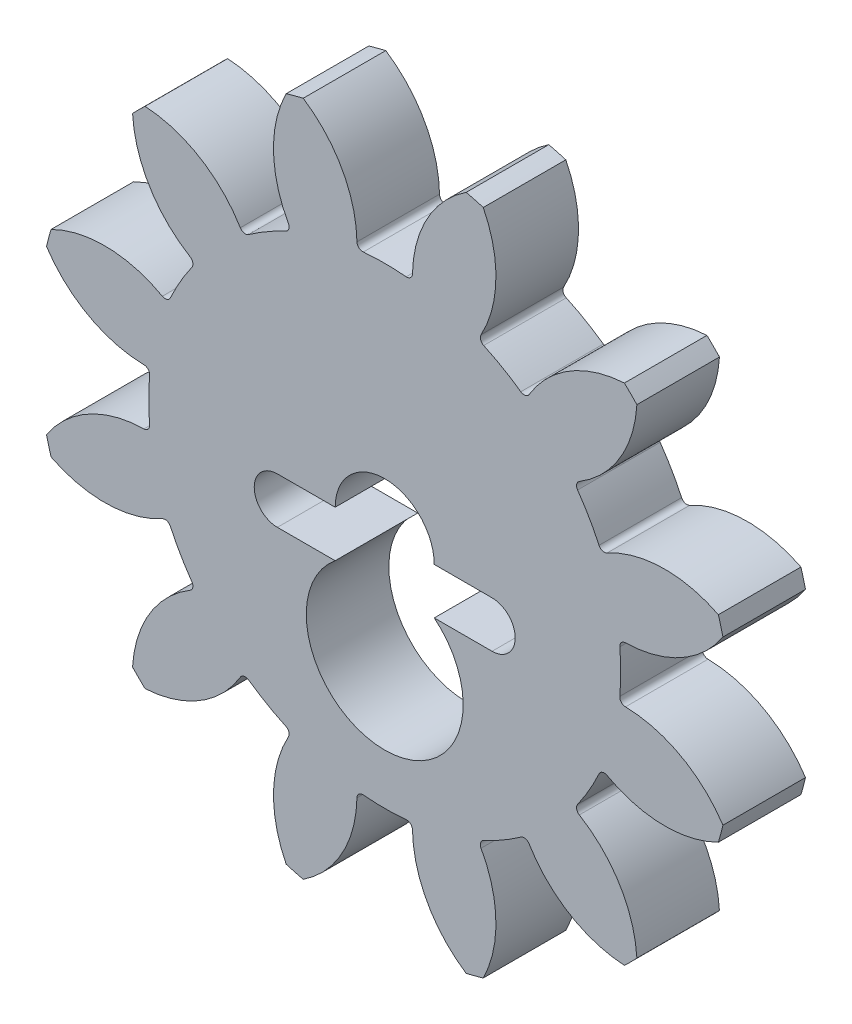
from build123d import *

# Parameters (mm, degrees)
BOSS_EXTRUDE1_DEPTH = 2.54
FILLET1_R           = 0.1778


with BuildPart() as part:
    # Sketch1 → Boss-Extrude1 (new body)
    with BuildSketch(Plane.XY):
        with BuildLine():
            ThreePointArc((-7.372965122, 7.75726334), (-7.56755407, 7.56755407), (-7.75726334, 7.372965122))
            ThreePointArc((-7.75726334, 7.372965122), (-7.183443639, 5.605840676), (-5.817551904, 4.346341719))
            ThreePointArc((-5.817551904, 4.346341719), (-6.288954394, 3.630929512), (-6.672818294, 2.864976877))
            ThreePointArc((-6.672818294, 2.864976877), (-8.446522255, 3.41812434), (-10.263806767, 3.031504555))
            ThreePointArc((-10.263806767, 3.031504555), (-10.337471104, 2.769917034), (-10.404469677, 2.506543427))
            ThreePointArc((-10.404469677, 2.506543427), (-9.023965016, 1.263078615), (-7.211318596, 0.85526639))
            ThreePointArc((-7.211318596, 0.85526639), (-7.261859025, 0), (-7.211318596, -0.85526639))
            ThreePointArc((-7.211318596, -0.85526639), (-9.023965016, -1.263078615), (-10.404469677, -2.506543427))
            ThreePointArc((-10.404469677, -2.506543427), (-10.337471104, -2.769917034), (-10.263806767, -3.031504555))
            ThreePointArc((-10.263806767, -3.031504555), (-8.446522255, -3.41812434), (-6.672818294, -2.864976877))
            ThreePointArc((-6.672818294, -2.864976877), (-6.288954394, -3.630929512), (-5.817551904, -4.346341719))
            ThreePointArc((-5.817551904, -4.346341719), (-7.183443639, -5.605840676), (-7.75726334, -7.372965122))
            ThreePointArc((-7.75726334, -7.372965122), (-7.56755407, -7.56755407), (-7.372965122, -7.75726334))
            ThreePointArc((-7.372965122, -7.75726334), (-5.605840676, -7.183443639), (-4.346341719, -5.817551904))
            ThreePointArc((-4.346341719, -5.817551904), (-3.630929512, -6.288954394), (-2.864976877, -6.672818294))
            ThreePointArc((-2.864976877, -6.672818294), (-3.41812434, -8.446522255), (-3.031504555, -10.263806767))
            ThreePointArc((-3.031504555, -10.263806767), (-2.769917034, -10.337471104), (-2.506543427, -10.404469677))
            ThreePointArc((-2.506543427, -10.404469677), (-1.263078615, -9.023965016), (-0.85526639, -7.211318596))
            ThreePointArc((-0.85526639, -7.211318596), (0, -7.261859025), (0.85526639, -7.211318596))
            ThreePointArc((0.85526639, -7.211318596), (1.263078615, -9.023965016), (2.506543427, -10.404469677))
            ThreePointArc((2.506543427, -10.404469677), (2.769917034, -10.337471104), (3.031504555, -10.263806767))
            ThreePointArc((3.031504555, -10.263806767), (3.41812434, -8.446522255), (2.864976877, -6.672818294))
            ThreePointArc((2.864976877, -6.672818294), (3.630929512, -6.288954394), (4.346341719, -5.817551904))
            ThreePointArc((4.346341719, -5.817551904), (5.605840676, -7.183443639), (7.372965122, -7.75726334))
            ThreePointArc((7.372965122, -7.75726334), (7.56755407, -7.56755407), (7.75726334, -7.372965122))
            ThreePointArc((7.75726334, -7.372965122), (7.183443639, -5.605840676), (5.817551904, -4.346341719))
            ThreePointArc((5.817551904, -4.346341719), (6.288954394, -3.630929512), (6.672818294, -2.864976877))
            ThreePointArc((6.672818294, -2.864976877), (8.446522255, -3.41812434), (10.263806767, -3.031504555))
            ThreePointArc((10.263806767, -3.031504555), (10.337471104, -2.769917034), (10.404469677, -2.506543427))
            ThreePointArc((10.404469677, -2.506543427), (9.023965016, -1.263078615), (7.211318596, -0.85526639))
            ThreePointArc((7.211318596, -0.85526639), (7.261859025, 0), (7.211318596, 0.85526639))
            ThreePointArc((7.211318596, 0.85526639), (9.023965016, 1.263078615), (10.404469677, 2.506543427))
            ThreePointArc((10.404469677, 2.506543427), (10.337471104, 2.769917034), (10.263806767, 3.031504555))
            ThreePointArc((10.263806767, 3.031504555), (8.446522255, 3.41812434), (6.672818294, 2.864976877))
            ThreePointArc((6.672818294, 2.864976877), (6.288954394, 3.630929512), (5.817551904, 4.346341719))
            ThreePointArc((5.817551904, 4.346341719), (7.183443639, 5.605840676), (7.75726334, 7.372965122))
            ThreePointArc((7.75726334, 7.372965122), (7.56755407, 7.56755407), (7.372965122, 7.75726334))
            ThreePointArc((7.372965122, 7.75726334), (5.605840676, 7.183443639), (4.346341719, 5.817551904))
            ThreePointArc((4.346341719, 5.817551904), (3.630929512, 6.288954394), (2.864976877, 6.672818294))
            ThreePointArc((2.864976877, 6.672818294), (3.41812434, 8.446522255), (3.031504555, 10.263806767))
            ThreePointArc((3.031504555, 10.263806767), (2.769917034, 10.337471104), (2.506543427, 10.404469677))
            ThreePointArc((2.506543427, 10.404469677), (1.263078615, 9.023965016), (0.85526639, 7.211318596))
            ThreePointArc((0.85526639, 7.211318596), (0, 7.261859025), (-0.85526639, 7.211318596))
            ThreePointArc((-0.85526639, 7.211318596), (-1.263078615, 9.023965016), (-2.506543427, 10.404469677))
            ThreePointArc((-2.506543427, 10.404469677), (-2.769917034, 10.337471104), (-3.031504555, 10.263806767))
            ThreePointArc((-3.031504555, 10.263806767), (-3.41812434, 8.446522255), (-2.864976877, 6.672818294))
            ThreePointArc((-2.864976877, 6.672818294), (-3.630929512, 6.288954394), (-4.346341719, 5.817551904))
            ThreePointArc((-4.346341719, 5.817551904), (-5.605840676, 7.183443639), (-7.372965122, 7.75726334))
        make_face()
        with BuildLine():
            Line((-1.524, -1.424354318), (-3.302, -1.424354318))
            ThreePointArc((-3.302, -1.424354318), (-4.014177159, -0.712177159), (-3.302, 0))
            Line((-3.302, 0), (-1.524, 0))
            ThreePointArc((-1.524, 0), (0, 1.524), (1.524, 0))
            Line((1.524, 0), (3.302, 0))
            ThreePointArc((3.302, 0), (4.014177159, -0.712177159), (3.302, -1.424354318))
            Line((3.302, -1.424354318), (1.524, -1.424354318))
            ThreePointArc((1.524, -1.424354318), (0, -5.70818114), (-1.524, -1.424354318))
        make_face(mode=Mode.SUBTRACT)
    extrude(amount=BOSS_EXTRUDE1_DEPTH)

    # Fillet1
    fillet1_edges = [part.edges().sort_by_distance(p)[0] for p in [
        (-4.346341719, 5.817551904, 1.27),
        (-2.864976877, 6.672818294, 1.27),
        (-0.85526639, 7.211318596, 1.27),
        (0.85526639, 7.211318596, 1.27),
        (2.864976877, 6.672818294, 1.27),
        (4.346341719, 5.817551904, 1.27),
        (5.817551904, 4.346341719, 1.27),
        (6.672818294, 2.864976877, 1.27),
        (7.211318596, 0.85526639, 1.27),
        (7.211318596, -0.85526639, 1.27),
        (6.672818294, -2.864976877, 1.27),
        (5.817551904, -4.346341719, 1.27),
        (4.346341719, -5.817551904, 1.27),
        (2.864976877, -6.672818294, 1.27),
        (0.85526639, -7.211318596, 1.27),
        (-0.85526639, -7.211318596, 1.27),
        (-2.864976877, -6.672818294, 1.27),
        (-4.346341719, -5.817551904, 1.27),
        (-5.817551904, -4.346341719, 1.27),
        (-6.672818294, -2.864976877, 1.27),
        (-7.211318596, -0.85526639, 1.27),
        (-7.211318596, 0.85526639, 1.27),
        (-6.672818294, 2.864976877, 1.27),
        (-5.817551904, 4.346341719, 1.27),
    ]]
    fillet(fillet1_edges, radius=FILLET1_R)


solid = part.part
